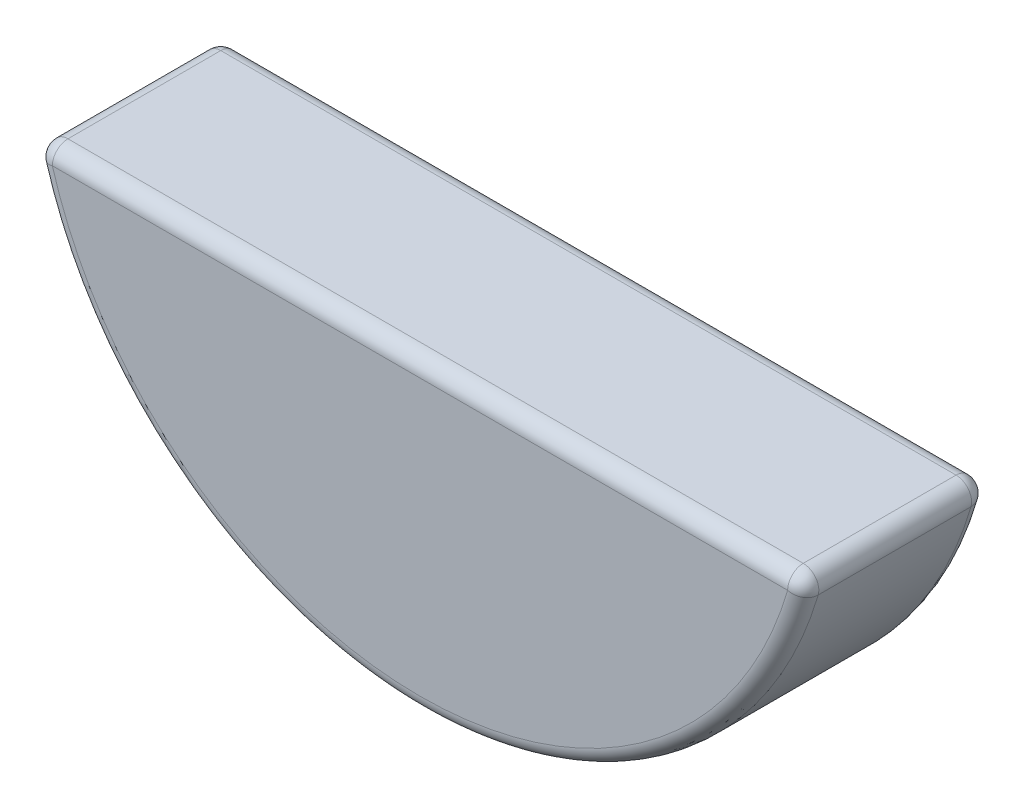
from build123d import *

# Parameters (mm, degrees)
EXTRUDE1_DEPTH = 1.5
FILLET1_R      = 0.254


with BuildPart() as part:
    # Sketch1 → Extrude1 (new body, symmetric)
    with BuildSketch(Plane.XY):
        with BuildLine():
            Line((-6.325, -1.498123827), (6.325, -1.498123827))
            ThreePointArc((6.325, -1.498123827), (0, -6.5), (-6.325, -1.498123827))
        make_face()
    extrude(amount=EXTRUDE1_DEPTH, both=True)

    # Fillet1
    fillet1_edges = [part.edges().sort_by_distance(p)[0] for p in [
        (0, -1.498123827, -1.5),
        (0, -6.5, -1.5),
        (0, -6.5, 1.5),
        (-6.325, -1.498123827, 0),
        (6.325, -1.498123827, 0),
        (0, -1.498123827, 1.5),
    ]]
    fillet(fillet1_edges, radius=FILLET1_R)


solid = part.part
